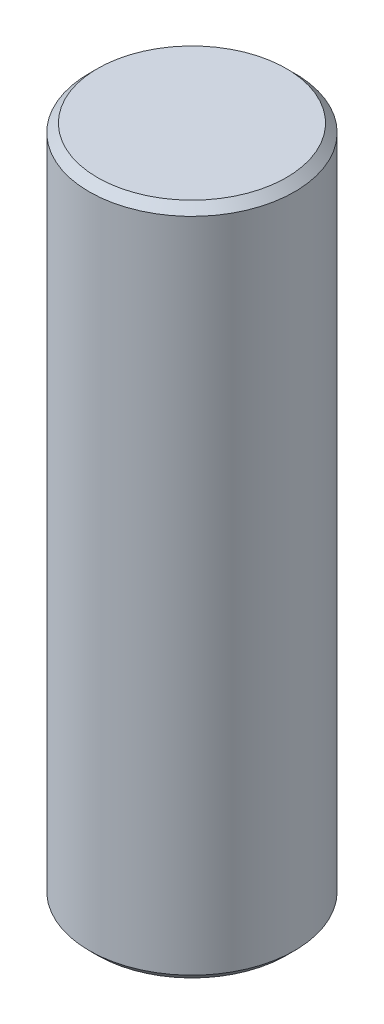
from build123d import *

# Parameters (mm, degrees)
SKETCH1_R           = 12.5
BOSS_EXTRUDE1_DEPTH = 82
CHAMFER2_SIZE       = 1


with BuildPart() as part:
    # Sketch1 → Boss-Extrude1 (new body)
    with BuildSketch(Plane(origin=(0, 0, 0), x_dir=(1, 0, 0), z_dir=(0, 1, 0))):
        Circle(SKETCH1_R)
    extrude(amount=BOSS_EXTRUDE1_DEPTH)

    # Chamfer2
    chamfer2_edges = [part.edges().sort_by_distance(p)[0] for p in [
        (-12.5, 0, 0),
        (-12.5, 82, 0),
    ]]
    chamfer(chamfer2_edges, length=CHAMFER2_SIZE)


solid = part.part
